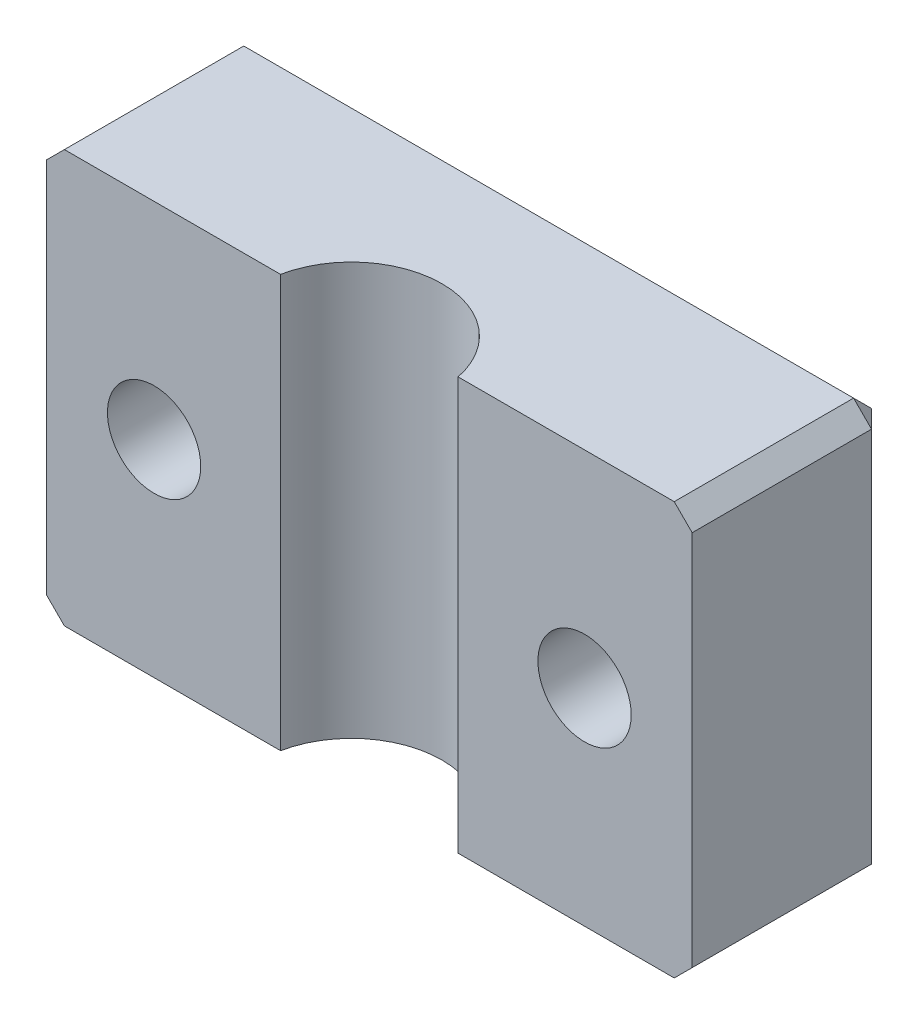
from build123d import *

# Parameters (mm, degrees)
BOSS_EXTRUDE1_DEPTH = 23
CUT_EXTRUDE1_REACH  = 13
SKETCH2_R           = 2.6
CHAMFER1_SIZE       = 1


with BuildPart() as part:
    # Sketch1 → Boss-Extrude1 (new body)
    with BuildSketch(Plane(origin=(0, 0, 0), x_dir=(1, 0, 0), z_dir=(0, 1, 0))):
        with BuildLine():
            Line((-18, 0), (18, 0))
            Line((18, 0), (18, -11))
            Line((18, -11), (4.95, -11))
            ThreePointArc((4.95, -11), (0, -6.95), (-4.95, -11))
            Line((-4.95, -11), (-18, -11))
            Line((-18, -11), (-18, 0))
        make_face()
    extrude(amount=BOSS_EXTRUDE1_DEPTH)

    # Sketch2 → Cut-Extrude1 (cut, up to next)
    with BuildSketch(Plane.XY.offset(11), mode=Mode.PRIVATE) as cut_extrude1_sk1:
        with Locations((-12, 11.5)):
            Circle(SKETCH2_R)
    cut_extrude1_tool1 = extrude(cut_extrude1_sk1.sketch, amount=-CUT_EXTRUDE1_REACH, mode=Mode.PRIVATE) & part.part
    add(cut_extrude1_tool1.solids().sort_by_distance((-12, 11.5, 11))[0], mode=Mode.SUBTRACT)
    # Sketch2 → Cut-Extrude1 (cut, up to next)
    with BuildSketch(Plane.XY.offset(11), mode=Mode.PRIVATE) as cut_extrude1_sk2:
        with Locations((12, 11.5)):
            Circle(SKETCH2_R)
    cut_extrude1_tool2 = extrude(cut_extrude1_sk2.sketch, amount=-CUT_EXTRUDE1_REACH, mode=Mode.PRIVATE) & part.part
    add(cut_extrude1_tool2.solids().sort_by_distance((12, 11.5, 11))[0], mode=Mode.SUBTRACT)

    # Chamfer1
    chamfer1_edges = [part.edges().sort_by_distance(p)[0] for p in [
        (-18, 11.5, 0),
        (18, 11.5, 0),
        (18, 23, 5.5),
        (0, 23, 0),
        (-18, 23, 5.5),
        (0, 0, 0),
        (18, 0, 5.5),
        (-18, 0, 5.5),
    ]]
    chamfer(chamfer1_edges, length=CHAMFER1_SIZE)


solid = part.part
